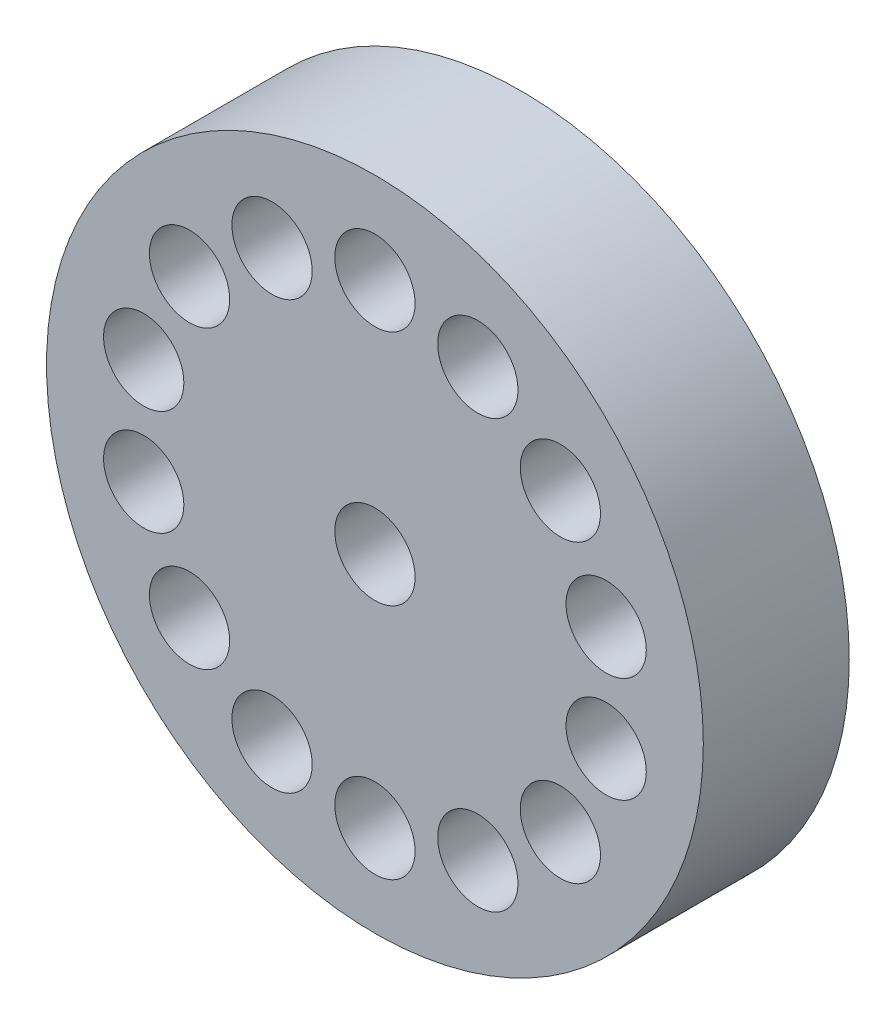
from build123d import *

# Parameters (mm, degrees)
SZKIC1_R                    = 4.5
SZKIC1_R_2                  = 0.55
DODANIE_WYCI_GNI_CIE1_DEPTH = 2
SZKIC2_R                    = 0.55
WYTNIJ_WYCI_GNI_CIE1_DEPTH  = 1


with BuildPart() as part:
    # Szkic1 → Dodanie-wyciągnięcie1 (new body)
    with BuildSketch(Plane.XY):
        Circle(SZKIC1_R)
        Circle(SZKIC1_R_2, mode=Mode.SUBTRACT)
    extrude(amount=DODANIE_WYCI_GNI_CIE1_DEPTH)

    # Szkic2 → Wytnij-wyciągnięcie1 (cut)
    with BuildSketch(Plane.XY.offset(2)):
        with Locations((0, 3.25)):
            Circle(SZKIC2_R)
        with Locations((1.410122152, 2.928148821)):
            Circle(SZKIC2_R)
        with Locations((2.540952318, 2.026341856)):
            Circle(SZKIC2_R)
        with Locations((3.168515715, 0.723193035)):
            Circle(SZKIC2_R)
        with Locations((3.168515715, -0.723193035)):
            Circle(SZKIC2_R)
        with Locations((2.540952318, -2.026341856)):
            Circle(SZKIC2_R)
        with Locations((1.410122152, -2.928148821)):
            Circle(SZKIC2_R)
        with Locations((0, -3.25)):
            Circle(SZKIC2_R)
        with Locations((-1.410122152, -2.928148821)):
            Circle(SZKIC2_R)
        with Locations((-2.540952318, -2.026341856)):
            Circle(SZKIC2_R)
        with Locations((-3.168515715, -0.723193035)):
            Circle(SZKIC2_R)
        with Locations((-3.168515715, 0.723193035)):
            Circle(SZKIC2_R)
        with Locations((-2.540952318, 2.026341856)):
            Circle(SZKIC2_R)
        with Locations((-1.410122152, 2.928148821)):
            Circle(SZKIC2_R)
    extrude(amount=-WYTNIJ_WYCI_GNI_CIE1_DEPTH, mode=Mode.SUBTRACT)


solid = part.part
